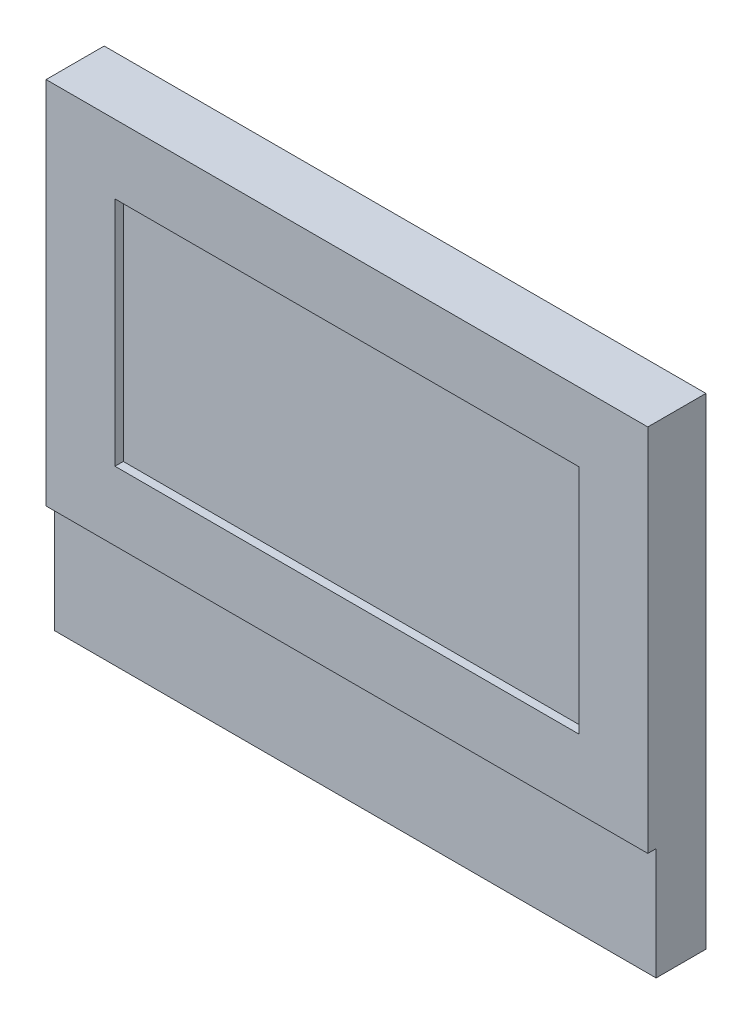
from build123d import *

# Parameters (mm, degrees)
SKETCH1_W           = 145
SKETCH1_H           = 116
BOSS_EXTRUDE1_DEPTH = 12
SKETCH2_W           = 145
SKETCH2_H           = 89
SKETCH2_W_2         = 111.8
SKETCH2_H_2         = 55.8
BOSS_EXTRUDE2_DEPTH = 2


with BuildPart() as part:
    # Sketch1 → Boss-Extrude1 (new body)
    with BuildSketch(Plane.XY):
        Rectangle(SKETCH1_W, SKETCH1_H)
    extrude(amount=BOSS_EXTRUDE1_DEPTH)

    # Sketch2 → Boss-Extrude2 (add)
    with BuildSketch(Plane.XY.offset(12)):
        with Locations((0, 13.5)):
            Rectangle(SKETCH2_W, SKETCH2_H)
        with Locations((0, 13.5)):
            Rectangle(SKETCH2_W_2, SKETCH2_H_2, mode=Mode.SUBTRACT)
    extrude(amount=BOSS_EXTRUDE2_DEPTH)


solid = part.part
